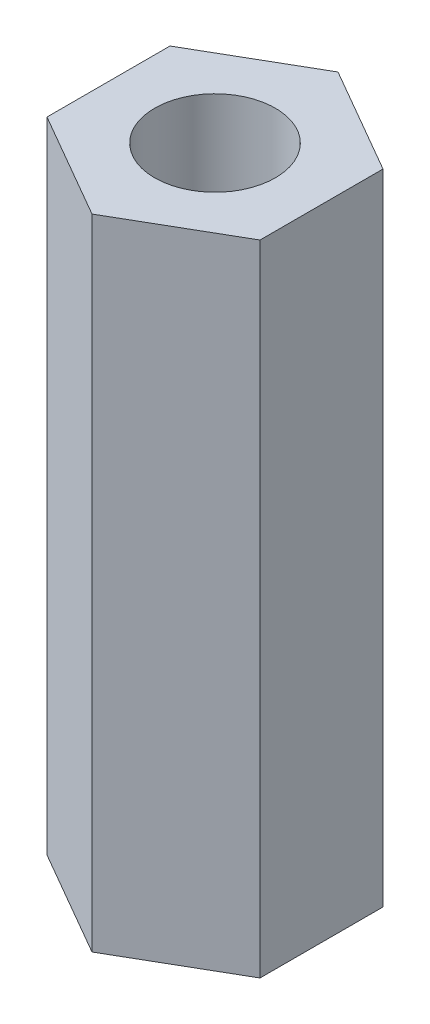
from build123d import *

# Parameters (mm, degrees)
SKETCH1_R           = 0.85
BOSS_EXTRUDE1_DEPTH = 9


with BuildPart() as part:
    # Sketch1 → Boss-Extrude1 (new body)
    with BuildSketch(Plane(origin=(0, 0, 0), x_dir=(1, 0, 0), z_dir=(0, 1, 0))):
        Polygon((0, -1.732050808), (1.5, -0.866025404), (1.5, 0.866025404), (0, 1.732050808), (-1.5, 0.866025404), (-1.5, -0.866025404), align=None)
        Circle(SKETCH1_R, mode=Mode.SUBTRACT)
    extrude(amount=BOSS_EXTRUDE1_DEPTH)


solid = part.part
